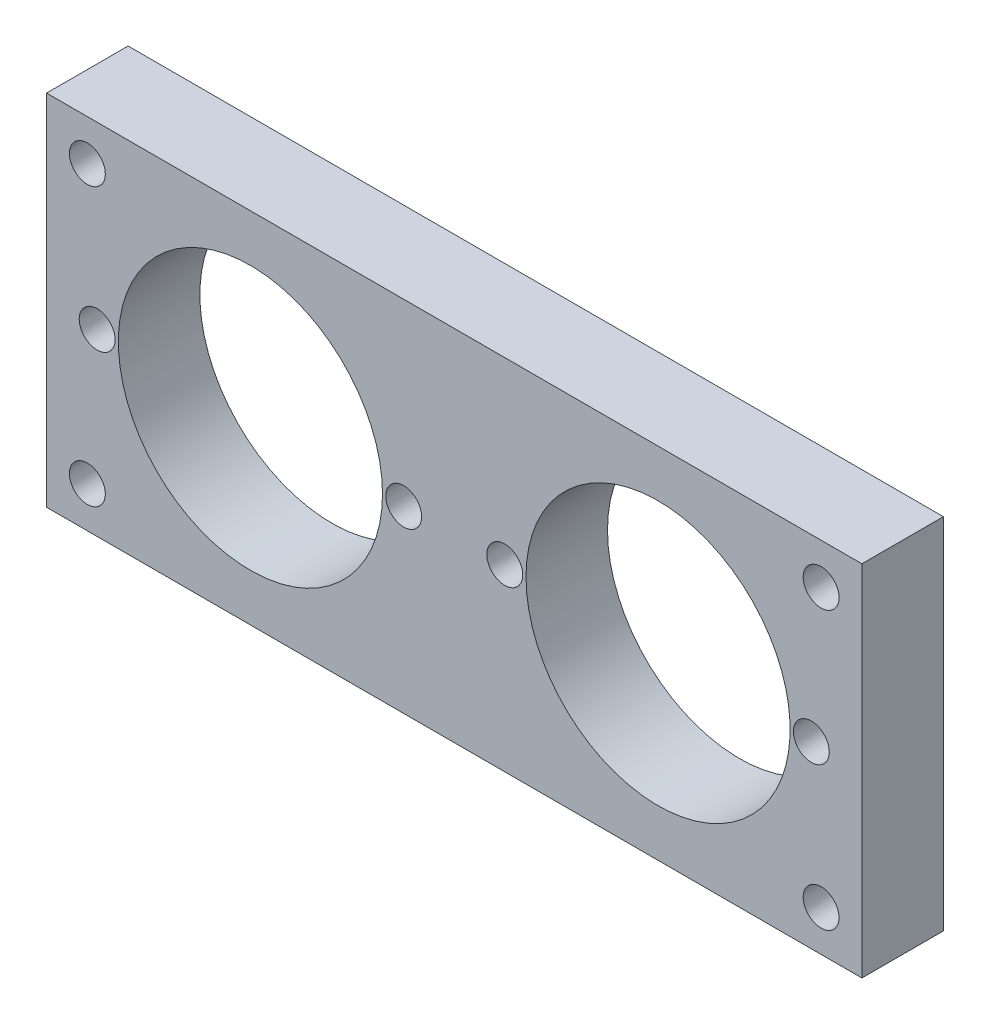
from build123d import *

# Parameters (mm, degrees)
SKETCH_1_W      = 50
SKETCH_1_H      = 22
SKETCH_1_R      = 1.1
SKETCH_1_R_2    = 8.1
EXTRUDE_1_DEPTH = 5


with BuildPart() as part:
    # 草图1 → 凸台-拉伸1 (new body)
    with BuildSketch(Plane.XY):
        Rectangle(SKETCH_1_W, SKETCH_1_H)
        with Locations((-22.5, 8.5)):
            Circle(SKETCH_1_R, mode=Mode.SUBTRACT)
        with Locations((22.5, 8.5)):
            Circle(SKETCH_1_R, mode=Mode.SUBTRACT)
        with Locations((22.5, -8.5)):
            Circle(SKETCH_1_R, mode=Mode.SUBTRACT)
        with Locations((-22.5, -8.5)):
            Circle(SKETCH_1_R, mode=Mode.SUBTRACT)
        with Locations((-12.5, 0)):
            Circle(SKETCH_1_R_2, mode=Mode.SUBTRACT)
        with Locations((12.5, 0)):
            Circle(SKETCH_1_R_2, mode=Mode.SUBTRACT)
        with Locations((21.9, 0)):
            Circle(SKETCH_1_R, mode=Mode.SUBTRACT)
        with Locations((-21.9, 0)):
            Circle(SKETCH_1_R, mode=Mode.SUBTRACT)
        with Locations((3.1, 0)):
            Circle(SKETCH_1_R, mode=Mode.SUBTRACT)
        with Locations((-3.1, 0)):
            Circle(SKETCH_1_R, mode=Mode.SUBTRACT)
    extrude(amount=EXTRUDE_1_DEPTH)


solid = part.part
